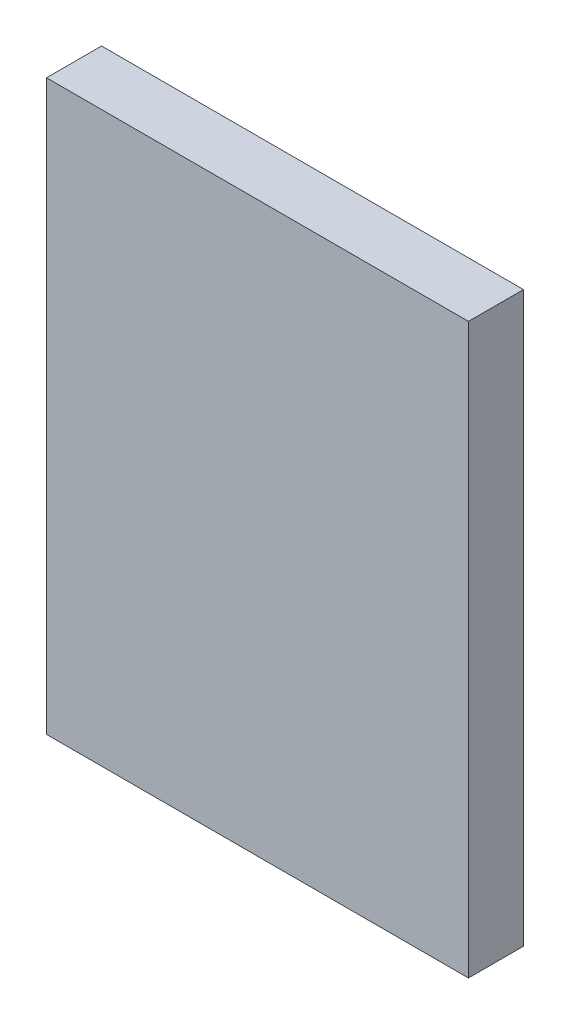
from build123d import *

# Parameters (mm, degrees)
ESQUISSE1_W        = 23
ESQUISSE1_H        = 31
BOSS_EXTRU_1_DEPTH = 3


with BuildPart() as part:
    # Esquisse1 → Boss.-Extru.1 (new body)
    with BuildSketch(Plane.XY):
        Rectangle(ESQUISSE1_W, ESQUISSE1_H)
    extrude(amount=BOSS_EXTRU_1_DEPTH)


solid = part.part
